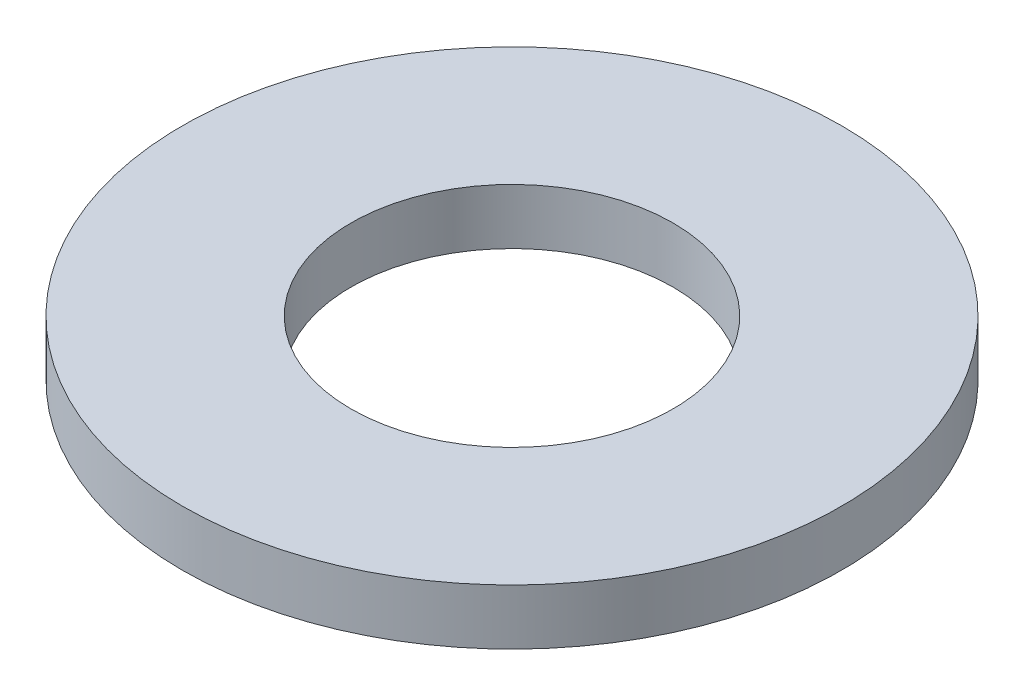
from build123d import *

# Parameters (mm, degrees)
SKETCH2_R           = 4.45
SKETCH2_R_2         = 2.175
BOSS_EXTRUDE1_DEPTH = 0.75


with BuildPart() as part:
    # Sketch2 → Boss-Extrude1 (new body)
    with BuildSketch(Plane(origin=(0, 0, 0), x_dir=(1, 0, 0), z_dir=(0, 1, 0))):
        Circle(SKETCH2_R)
        Circle(SKETCH2_R_2, mode=Mode.SUBTRACT)
    extrude(amount=BOSS_EXTRUDE1_DEPTH)


solid = part.part
